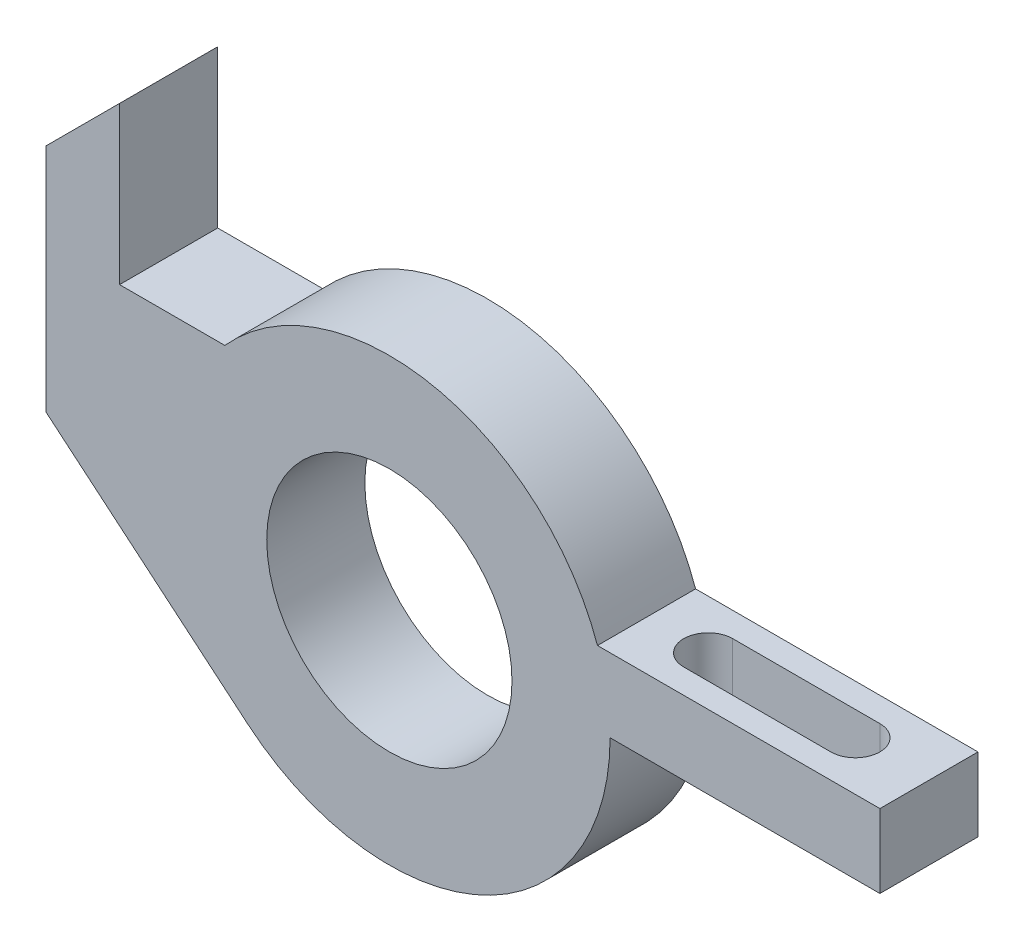
from build123d import *

# Parameters (mm, degrees)
SKETCH1_R           = 25
BOSS_EXTRUDE1_DEPTH = 20
CUT_EXTRUDE1_DEPTH  = 61


with BuildPart() as part:
    # Sketch1 → Boss-Extrude1 (new body)
    with BuildSketch(Plane.XY):
        with BuildLine():
            Line((-70, 0), (-28.928571429, -34.469374162))
            ThreePointArc((-28.928571429, -34.469374162), (19.015970731, -40.784713523), (45, 0))
            Line((45, 0), (100, 0))
            Line((100, 0), (100, 15))
            Line((100, 15), (42.426406871, 15))
            ThreePointArc((42.426406871, 15), (8.717082451, 44.14762138), (-33.541019662, 30))
            Line((-33.541019662, 30), (-55, 30))
            Line((-55, 30), (-55, 62))
            Line((-55, 62), (-70, 47))
            Line((-70, 47), (-70, 0))
        make_face()
        Circle(SKETCH1_R, mode=Mode.SUBTRACT)
    extrude(amount=BOSS_EXTRUDE1_DEPTH)

    # Sketch2 → Cut-Extrude1 (cut, through all)
    with BuildSketch(Plane(origin=(0, 15, 0), x_dir=(1, 0, 0), z_dir=(0, 1, 0))):
        with BuildLine():
            Line((55, -15), (85, -15))
            ThreePointArc((85, -15), (90, -10), (85, -5))
            Line((85, -5), (55, -5))
            ThreePointArc((55, -5), (50, -10), (55, -15))
        make_face()
    extrude(amount=-CUT_EXTRUDE1_DEPTH, mode=Mode.SUBTRACT)


solid = part.part
